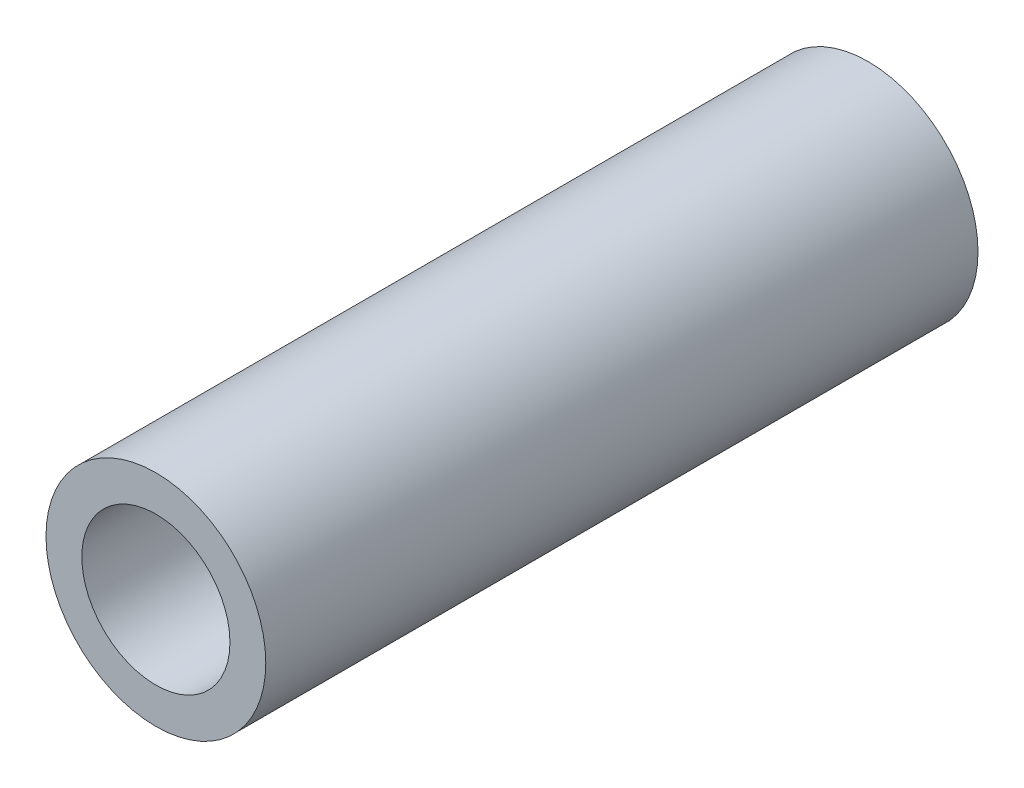
from build123d import *

# Parameters (mm, degrees)
SKETCH1_R      = 6.858
SKETCH1_R_2    = 4.6228
EXTRUDE1_DEPTH = 22.225


with BuildPart() as part:
    # Sketch1 → Extrude1 (new body, symmetric)
    with BuildSketch(Plane.XY):
        Circle(SKETCH1_R)
        Circle(SKETCH1_R_2, mode=Mode.SUBTRACT)
    extrude(amount=EXTRUDE1_DEPTH, both=True)


solid = part.part
